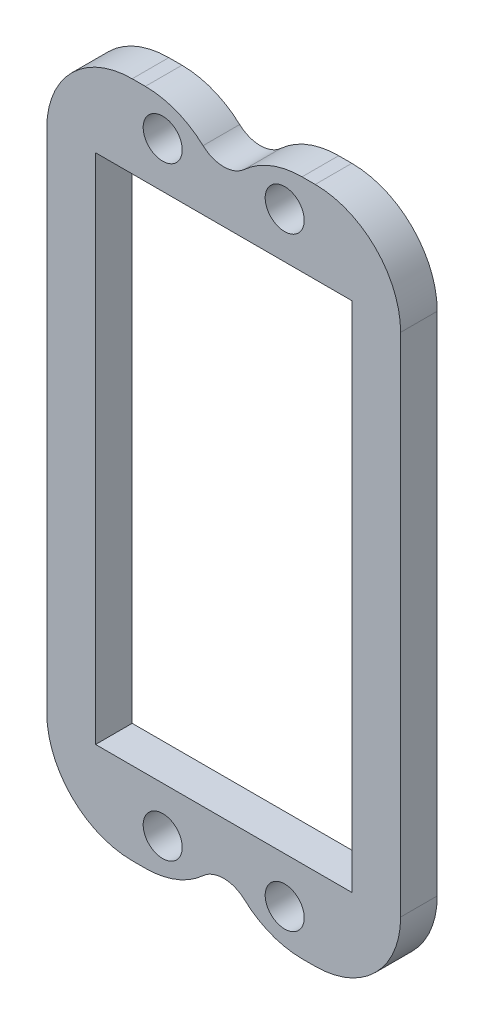
from build123d import *

# Parameters (mm, degrees)
ESBO_O1_R                = 1.6
ESBO_O1_W                = 21
ESBO_O1_H                = 42
RESSALTO_EXTRUS_O1_DEPTH = 3
FILETE1_R                = 7


with BuildPart() as part:
    # Esboço1 → Ressalto-extrusão1 (new body)
    with BuildSketch(Plane.XY):
        with BuildLine():
            Line((-14.5, 27.75), (-14.5, -27.75))
            Line((-14.5, -27.75), (-2.5, -27.75))
            ThreePointArc((-2.5, -27.75), (0, -25.25), (2.5, -27.75))
            Line((2.5, -27.75), (14.5, -27.75))
            Line((14.5, -27.75), (14.5, 27.75))
            Line((14.5, 27.75), (2.5, 27.75))
            ThreePointArc((2.5, 27.75), (0, 25.25), (-2.5, 27.75))
            Line((-2.5, 27.75), (-14.5, 27.75))
        make_face()
        with Locations((-5, -24.75)):
            Circle(ESBO_O1_R, mode=Mode.SUBTRACT)
        with Locations((5, -24.75)):
            Circle(ESBO_O1_R, mode=Mode.SUBTRACT)
        Rectangle(ESBO_O1_W, ESBO_O1_H, mode=Mode.SUBTRACT)
        with Locations((-5, 24.75)):
            Circle(ESBO_O1_R, mode=Mode.SUBTRACT)
        with Locations((5, 24.75)):
            Circle(ESBO_O1_R, mode=Mode.SUBTRACT)
    extrude(amount=RESSALTO_EXTRUS_O1_DEPTH)

    # Filete1
    filete1_edges = [part.edges().sort_by_distance(p)[0] for p in [
        (14.5, -27.75, 1.5),
        (-14.5, -27.75, 1.5),
        (-14.5, 27.75, 1.5),
        (14.5, 27.75, 1.5),
        (2.5, -27.75, 1.5),
        (-2.5, -27.75, 1.5),
        (2.5, 27.75, 1.5),
        (-2.5, 27.75, 1.5),
    ]]
    fillet(filete1_edges, radius=FILETE1_R)


solid = part.part
